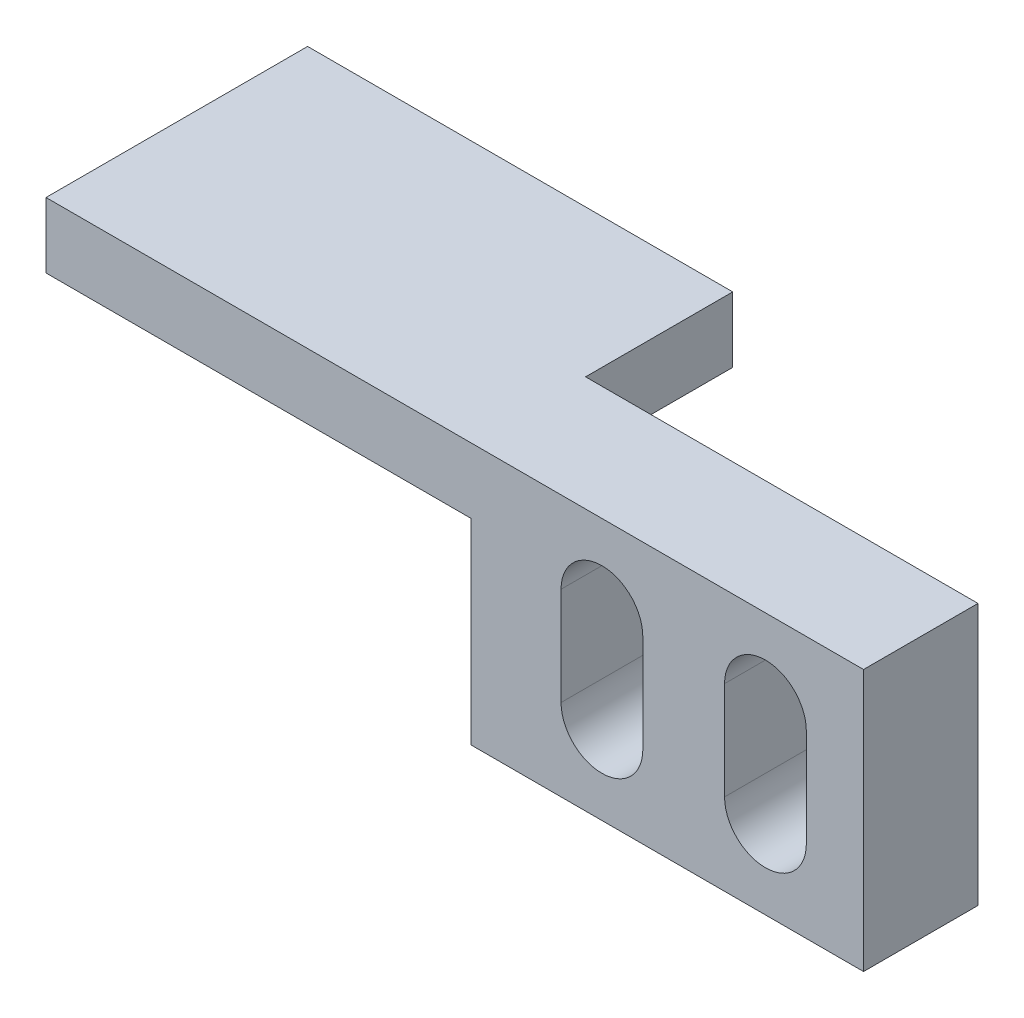
from build123d import *

# Parameters (mm, degrees)
SKETCH1_W           = 12
SKETCH1_H           = 8
BOSS_EXTRUDE1_DEPTH = 3.5
CUT_EXTRUDE1_DEPTH  = 4.5
SKETCH3_W           = 3.5
SKETCH3_H           = 2
BOSS_EXTRUDE2_DEPTH = 13
SKETCH4_W           = 13
SKETCH4_H           = 2
BOSS_EXTRUDE3_DEPTH = 4.5


with BuildPart() as part:
    # Sketch1 → Boss-Extrude1 (new body)
    with BuildSketch(Plane.XY):
        with Locations((6, 4)):
            Rectangle(SKETCH1_W, SKETCH1_H)
    extrude(amount=BOSS_EXTRUDE1_DEPTH)

    # Sketch2 → Cut-Extrude1 (cut, through all)
    with BuildSketch(Plane.XY.offset(3.5)):
        with BuildLine():
            Line((5.25, 5.5), (5.25, 2.5))
            ThreePointArc((5.25, 2.5), (4, 1.25), (2.75, 2.5))
            Line((2.75, 2.5), (2.75, 5.5))
            ThreePointArc((2.75, 5.5), (4, 6.75), (5.25, 5.5))
        make_face()
        with BuildLine():
            Line((10.25, 5.5), (10.25, 2.5))
            ThreePointArc((10.25, 2.5), (9, 1.25), (7.75, 2.5))
            Line((7.75, 2.5), (7.75, 5.5))
            ThreePointArc((7.75, 5.5), (9, 6.75), (10.25, 5.5))
        make_face()
    extrude(amount=-CUT_EXTRUDE1_DEPTH, mode=Mode.SUBTRACT)

    # Sketch3 → Boss-Extrude2 (add)
    with BuildSketch(Plane.ZY):
        with Locations((1.75, 7)):
            Rectangle(SKETCH3_W, SKETCH3_H)
    extrude(amount=BOSS_EXTRUDE2_DEPTH)

    # Sketch4 → Boss-Extrude3 (add)
    with BuildSketch(Plane(origin=(0, 0, 0), x_dir=(-1, 0, 0), z_dir=(0, 0, -1))):
        with Locations((6.5, 7)):
            Rectangle(SKETCH4_W, SKETCH4_H)
    extrude(amount=BOSS_EXTRUDE3_DEPTH)


solid = part.part
